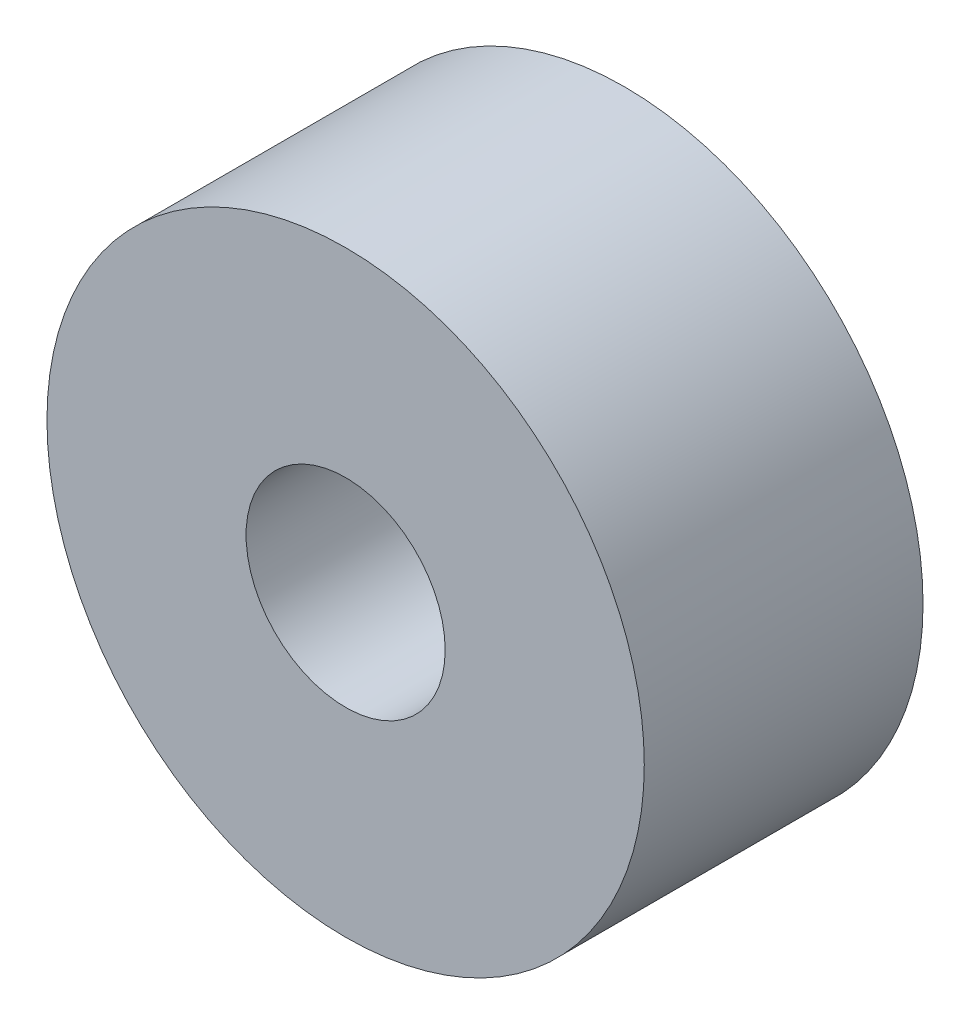
from build123d import *

# Parameters (mm, degrees)
SKETCH1_R           = 3
SKETCH1_R_2         = 1
BOSS_EXTRUDE1_DEPTH = 2.8


with BuildPart() as part:
    # Sketch1 → Boss-Extrude1 (new body)
    with BuildSketch(Plane.XY):
        Circle(SKETCH1_R)
        Circle(SKETCH1_R_2, mode=Mode.SUBTRACT)
    extrude(amount=BOSS_EXTRUDE1_DEPTH)


solid = part.part
